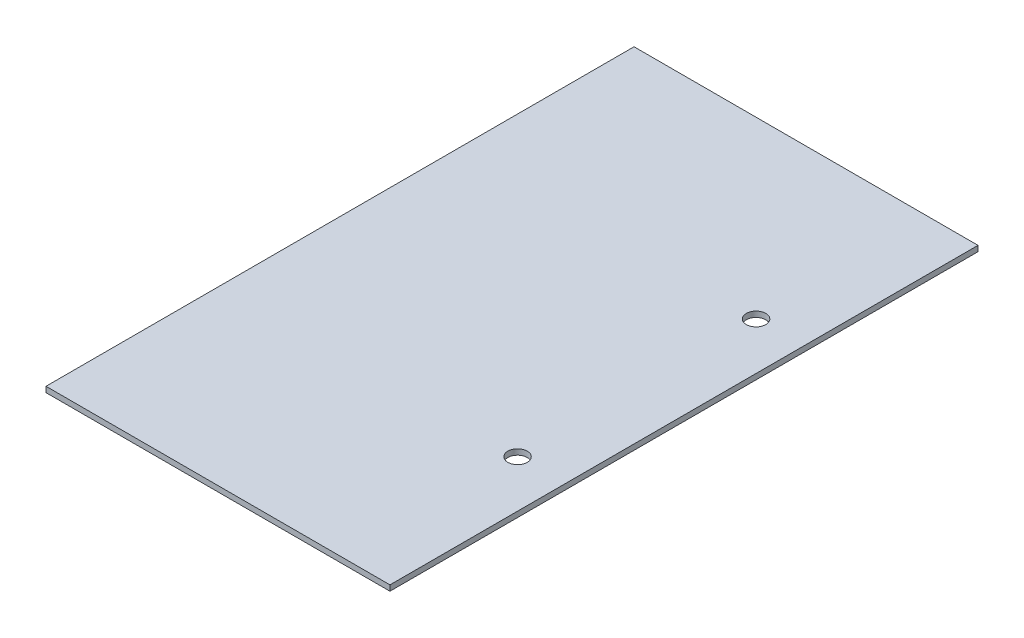
from build123d import *

# Parameters (mm, degrees)
SKETCH1_W           = 62
SKETCH1_H           = 106
SKETCH1_R           = 1.75
BOSS_EXTRUDE1_DEPTH = 1
SKETCH2_R           = 5
BOSS_EXTRUDE2_DEPTH = 17
FILLET1_R           = 5


with BuildPart() as part:
    # Sketch1 → Boss-Extrude1 (new body)
    with BuildSketch(Plane(origin=(0, 0, 0), x_dir=(1, 0, 0), z_dir=(0, 1, 0))):
        Rectangle(SKETCH1_W, SKETCH1_H)
        with Locations((22.5, -21.5)):
            Circle(SKETCH1_R, mode=Mode.SUBTRACT)
        with Locations((22.5, 21.5)):
            Circle(SKETCH1_R, mode=Mode.SUBTRACT)
    extrude(amount=BOSS_EXTRUDE1_DEPTH)

    # Sketch2 → Boss-Extrude2 (add)
    with BuildSketch(Plane.XZ):
        Circle(SKETCH2_R)
    extrude(amount=BOSS_EXTRUDE2_DEPTH)

    # Fillet1
    fillet1_edges = [part.edges().sort_by_distance(p)[0] for p in [
        (-5, -17, 0),
    ]]
    fillet(fillet1_edges, radius=FILLET1_R)


solid = part.part
